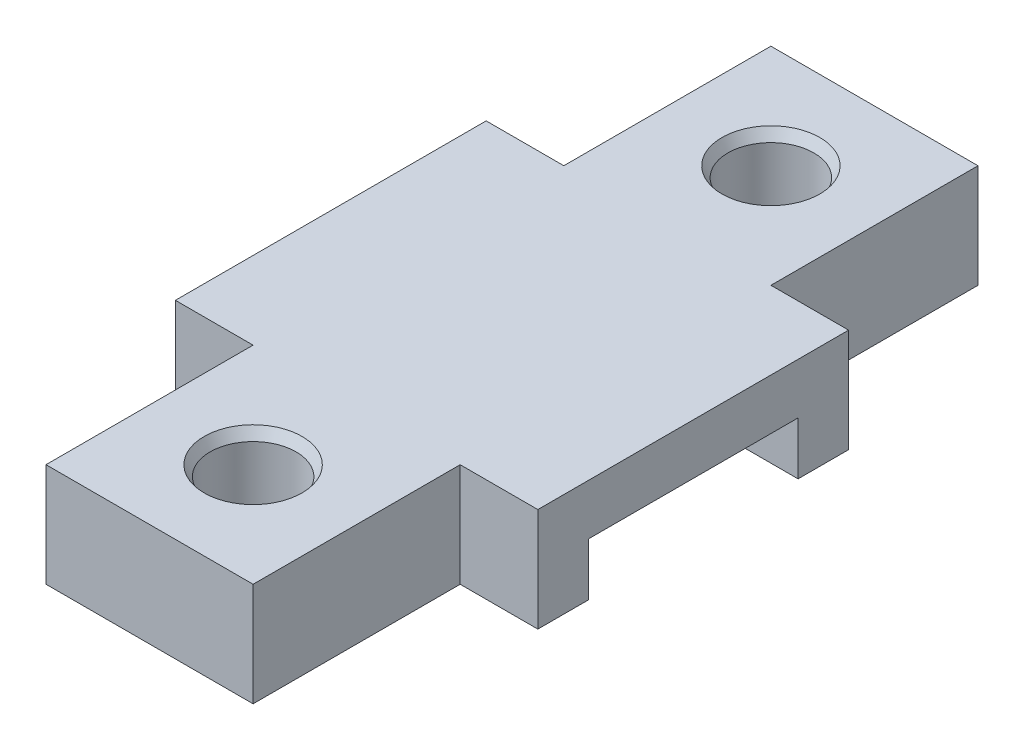
from build123d import *

# Parameters (mm, degrees)
SKETCH1_W                = 20
SKETCH1_H                = 70
BOSS_EXTRUDE1_DEPTH      = 10
SKETCH2_W                = 20.25
SKETCH2_H                = 5.1
CUT_EXTRUDE1_DEPTH       = 1
CUT_EXTRUDE1_DEPTH_BACK  = 21
SKETCH3_R                = 4.15
CUT_EXTRUDE2_DEPTH       = 11
BOSS_EXTRUDE2_DEPTH      = 7.5
BOSS_EXTRUDE2_DEPTH_BACK = 27.5
CHAMFER1_SIZE            = 1
CHAMFER1_SIZE2           = 0.577350269
CHAMFER1_PART_2_SIZE     = 1
CHAMFER1_PART_2_SIZE2    = 0.577350269


with BuildPart() as part:
    # Sketch1 → Boss-Extrude1 (new body)
    with BuildSketch(Plane(origin=(0, 0, 0), x_dir=(1, 0, 0), z_dir=(0, 1, 0))):
        Rectangle(SKETCH1_W, SKETCH1_H)
    extrude(amount=BOSS_EXTRUDE1_DEPTH)

    # Sketch2 → Cut-Extrude1 (cut, two sides)
    with BuildSketch(Plane(origin=(10, 0, 0), x_dir=(0, 0, -1), z_dir=(1, 0, 0))) as cut_extrude1_sk:
        with Locations((0, 2.55)):
            Rectangle(SKETCH2_W, SKETCH2_H)
    extrude(amount=CUT_EXTRUDE1_DEPTH, mode=Mode.SUBTRACT)
    extrude(cut_extrude1_sk.sketch, amount=-CUT_EXTRUDE1_DEPTH_BACK, mode=Mode.SUBTRACT)

    # Sketch3 → Cut-Extrude2 (cut, through all)
    with BuildSketch(Plane.XZ):
        with Locations(Location((0, 25, 0), (0, 0, 270))):  # turned: the seam where the file's is
            Circle(SKETCH3_R)
        with Locations(Location((0, -25, 0), (0, 0, 270))):  # turned: the seam where the file's is
            Circle(SKETCH3_R)
    extrude(amount=-CUT_EXTRUDE2_DEPTH, mode=Mode.SUBTRACT)

    # Sketch4 → Boss-Extrude2 (add, two sides)
    with BuildSketch(Plane(origin=(10, 0, 0), x_dir=(0, 0, -1), z_dir=(1, 0, 0))) as boss_extrude2_sk:
        Polygon((-10.125, 0), (-15.005, 0), (-15.005, 10), (15.005, 10), (15.005, 0), (10.125, 0), (10.125, 5.1), (-10.125, 5.1), align=None)
    extrude(amount=BOSS_EXTRUDE2_DEPTH)
    extrude(boss_extrude2_sk.sketch, amount=-BOSS_EXTRUDE2_DEPTH_BACK)

    # Chamfer1
    chamfer1_edges = [part.edges().sort_by_distance(p)[0] for p in [
        (0, 10, 29.15),
    ]]
    chamfer1_side = [part.faces().sort_by_distance(p)[0] for p in [
        (0, 5, 29.15),
    ]]
    chamfer(chamfer1_edges, length=CHAMFER1_SIZE, length2=CHAMFER1_SIZE2, reference=chamfer1_side[0])

    # Chamfer1 part 2
    chamfer1_part_2_edges = [part.edges().sort_by_distance(p)[0] for p in [
        (0, 10, -20.85),
    ]]
    chamfer1_part_2_side = [part.faces().sort_by_distance(p)[0] for p in [
        (0, 5, -20.85),
    ]]
    chamfer(chamfer1_part_2_edges, length=CHAMFER1_PART_2_SIZE, length2=CHAMFER1_PART_2_SIZE2, reference=chamfer1_part_2_side[0])


solid = part.part
